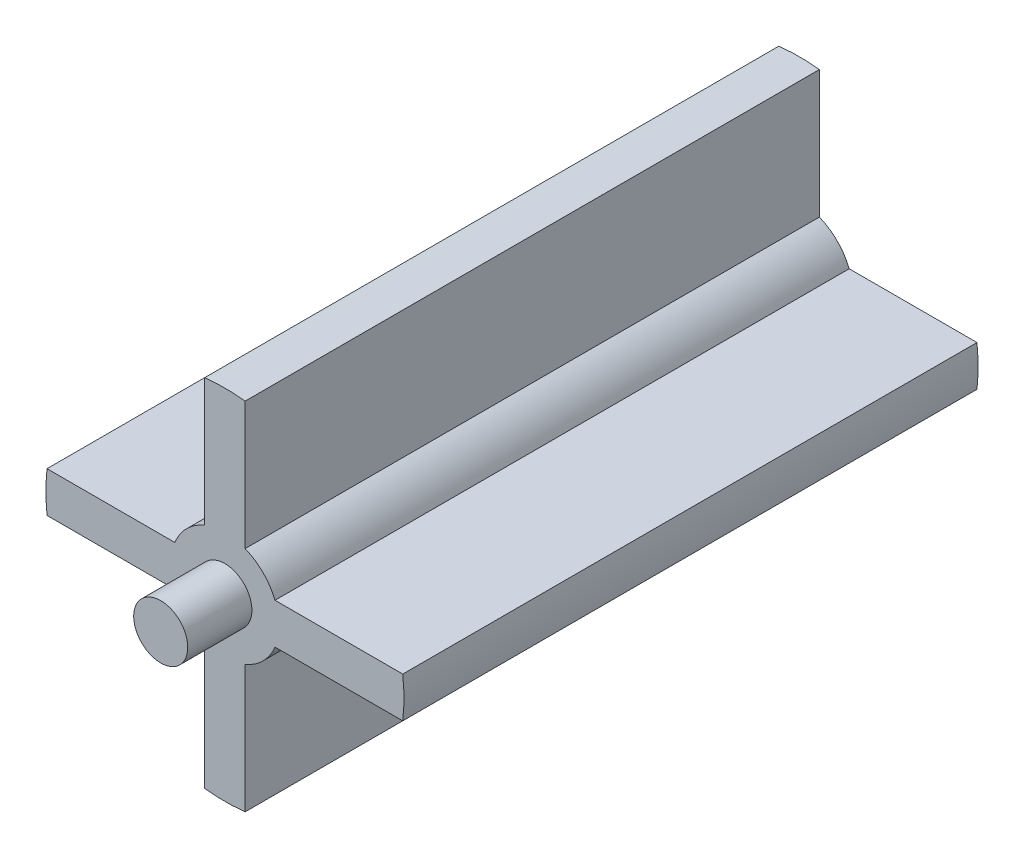
from build123d import *

# Parameters (mm, degrees)
SKETCH1_R           = 26.5
BOSS_EXTRUDE1_DEPTH = 85
SKETCH3_R           = 4
CUT_EXTRUDE2_DEPTH  = 5
SKETCH4_OUTSIDE_W   = 77.666
SKETCH4_OUTSIDE_H   = 77.666
CUT_EXTRUDE3_DEPTH  = 86
SKETCH5_R           = 3.975
BOSS_EXTRUDE2_DEPTH = 14.5
SKETCH2_R           = 4
BOSS_EXTRUDE3_DEPTH = 9.5


with BuildPart() as part:
    # Sketch1 → Boss-Extrude1 (new body)
    with BuildSketch(Plane.XY):
        Circle(SKETCH1_R)
    extrude(amount=BOSS_EXTRUDE1_DEPTH)

    # Sketch3 → Cut-Extrude2 (cut)
    with BuildSketch(Plane(origin=(0, 0, 0), x_dir=(-1, 0, 0), z_dir=(0, 0, -1))):
        Circle(SKETCH3_R)
    extrude(amount=-CUT_EXTRUDE2_DEPTH, mode=Mode.SUBTRACT)

    # Sketch4 outside → Cut-Extrude3 (cut, through all)
    with BuildSketch(Plane(origin=(0, 0, 0), x_dir=(-1, 0, 0), z_dir=(0, 0, -1))):
        Rectangle(SKETCH4_OUTSIDE_W, SKETCH4_OUTSIDE_H)
        with BuildLine():
            Line((-26.329641091, 3), (-7.416198487, 3))
            ThreePointArc((-7.416198487, 3), (-5.656854249, 5.656854249), (-3, 7.416198487))
            Line((-3, 7.416198487), (-3, 26.329641091))
            ThreePointArc((-3, 26.329641091), (0, 26.5), (3, 26.329641091))
            Line((3, 26.329641091), (3, 7.416198487))
            ThreePointArc((3, 7.416198487), (5.656854249, 5.656854249), (7.416198487, 3))
            Line((7.416198487, 3), (26.329641091, 3))
            ThreePointArc((26.329641091, 3), (26.5, 0), (26.329641091, -3))
            Line((26.329641091, -3), (7.416198487, -3))
            ThreePointArc((7.416198487, -3), (5.656854249, -5.656854249), (3, -7.416198487))
            Line((3, -7.416198487), (3, -26.329641091))
            ThreePointArc((3, -26.329641091), (0, -26.5), (-3, -26.329641091))
            Line((-3, -26.329641091), (-3, -7.416198487))
            ThreePointArc((-3, -7.416198487), (-5.656854249, -5.656854249), (-7.416198487, -3))
            Line((-7.416198487, -3), (-26.329641091, -3))
            ThreePointArc((-26.329641091, -3), (-26.5, 0), (-26.329641091, 3))
        make_face(mode=Mode.SUBTRACT)
    extrude(amount=-CUT_EXTRUDE3_DEPTH, mode=Mode.SUBTRACT)

    # Sketch2 → Boss-Extrude3 (add)
    with BuildSketch(Plane.XY.offset(85)):
        Circle(SKETCH2_R)
    extrude(amount=BOSS_EXTRUDE3_DEPTH)


with BuildPart() as body_2:
    # Sketch5 → Boss-Extrude2 (new body)
    with BuildSketch(Plane.XY):
        with Locations((9.53294491, -9.218672001)):
            Circle(SKETCH5_R)
    extrude(amount=BOSS_EXTRUDE2_DEPTH)


solid = Compound([part.part, body_2.part])
